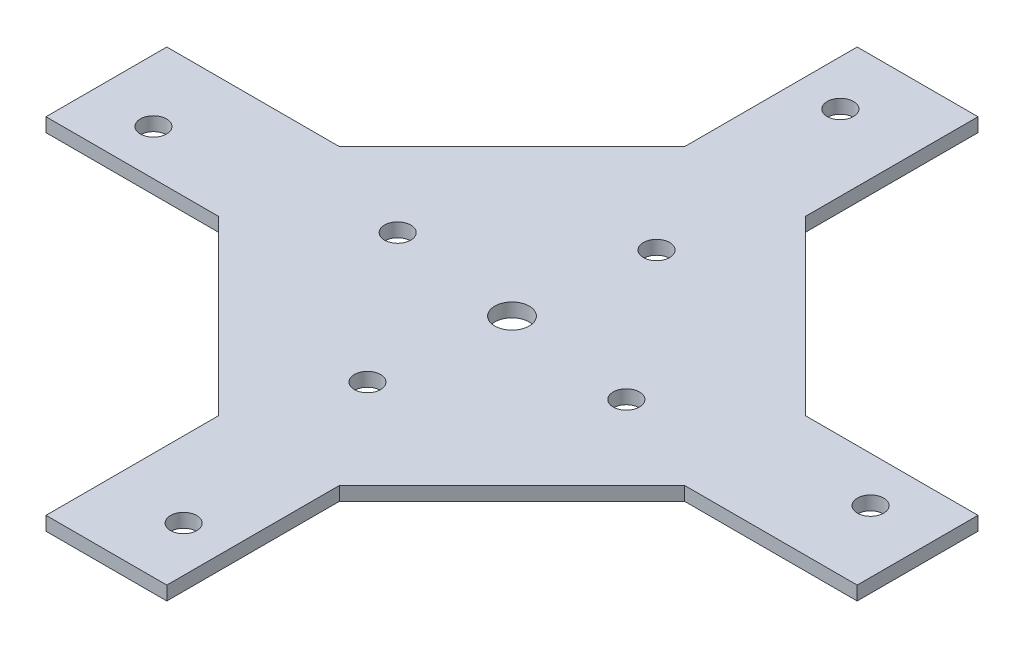
from build123d import *

# Parameters (mm, degrees)
SKETCH1_R           = 2.413
BOSS_EXTRUDE1_DEPTH = 2.54
SKETCH2_R           = 3.175
CUT_EXTRUDE1_DEPTH  = 3.54


with BuildPart() as part:
    # Sketch1 → Boss-Extrude1 (new body)
    with BuildSketch(Plane(origin=(0, 0, 0), x_dir=(1, 0, 0), z_dir=(0, 1, 0))):
        Polygon((-74.6125, -11.1125), (-74.6125, 11.1125), (-42.8625, 11.1125), (-11.1125, 42.8625), (-11.1125, 74.6125), (11.1125, 74.6125), (11.1125, 42.8625), (42.8625, 11.1125), (74.6125, 11.1125), (74.6125, -11.1125), (42.8625, -11.1125), (11.1125, -42.8625), (11.1125, -74.6125), (-11.1125, -74.6125), (-11.1125, -42.8625), (-42.8625, -11.1125), align=None)
        with Locations((-23.8125, 2.778125)):
            Circle(SKETCH1_R, mode=Mode.SUBTRACT)
        with Locations((-63.1825, -2.778125)):
            Circle(SKETCH1_R, mode=Mode.SUBTRACT)
        with Locations((-2.778125, 63.1825)):
            Circle(SKETCH1_R, mode=Mode.SUBTRACT)
        with Locations((2.778125, 23.8125)):
            Circle(SKETCH1_R, mode=Mode.SUBTRACT)
        with Locations((63.1825, 2.778125)):
            Circle(SKETCH1_R, mode=Mode.SUBTRACT)
        with Locations((23.8125, -2.778125)):
            Circle(SKETCH1_R, mode=Mode.SUBTRACT)
        with Locations((2.778125, -63.1825)):
            Circle(SKETCH1_R, mode=Mode.SUBTRACT)
        with Locations((-2.778125, -23.8125)):
            Circle(SKETCH1_R, mode=Mode.SUBTRACT)
    extrude(amount=BOSS_EXTRUDE1_DEPTH)

    # Sketch2 → Cut-Extrude1 (cut, through all)
    with BuildSketch(Plane(origin=(0, 2.54, 0), x_dir=(1, 0, 0), z_dir=(0, 1, 0))):
        Circle(SKETCH2_R)
    extrude(amount=-CUT_EXTRUDE1_DEPTH, mode=Mode.SUBTRACT)


solid = part.part
